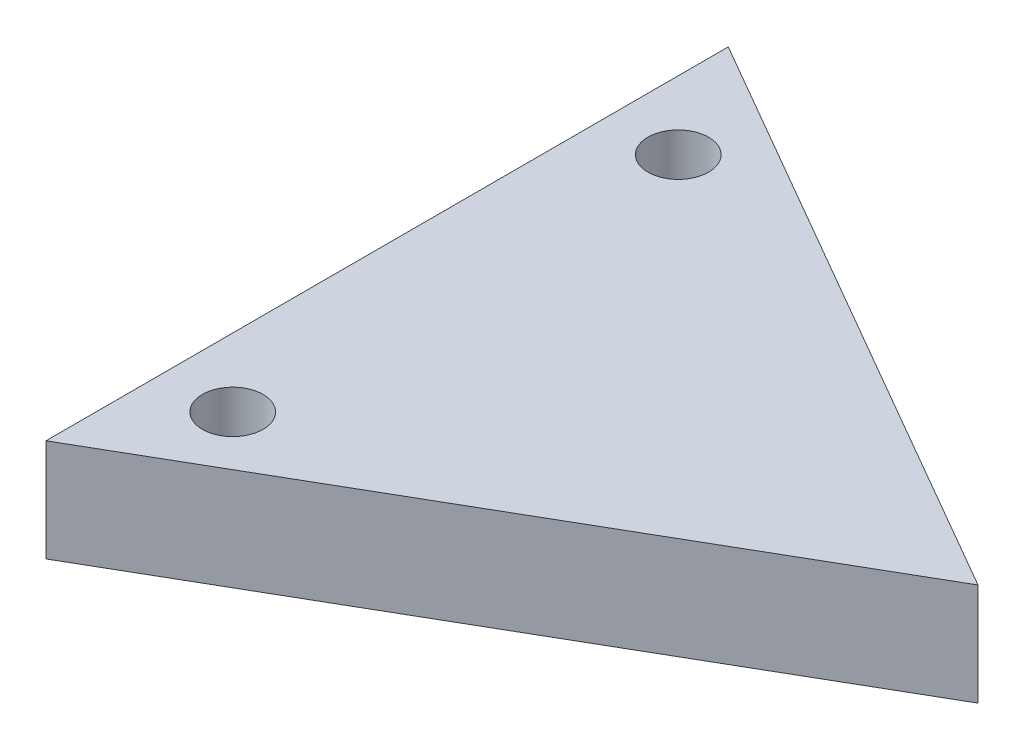
from build123d import *

# Parameters (mm, degrees)
EXTRUDE1_DEPTH  = 3
LPATTERN1_COUNT = 2
LPATTERN1_PITCH = 13.06


with BuildPart() as part:
    # Sketch1 → Extrude1 (new body)
    with BuildSketch(Plane(origin=(0, 0, 0), x_dir=(1, 0, 0), z_dir=(0, 1, 0))):
        Polygon((11.547005384, 0), (-5.773502692, 10), (-5.773502692, -10), align=None)
    extrude(amount=EXTRUDE1_DEPTH)

    # Sketch6 → #2-56 Tapped Hole1 (revolve, cut)
    with BuildSketch(Plane(origin=(-3.77, 3, -6.53), x_dir=(0, 0, 1), z_dir=(1, 0, 0))):
        Polygon((0, 0), (0, 7.17416509), (0.889, 6.64), (0.889, 0), align=None)
    f_2_56_tapped_hole1 = revolve(axis=Axis((-3.77, 9.35, -6.53), (0, -1, 0)), mode=Mode.SUBTRACT)

    # LPattern1: #2-56 Tapped Hole1 ×2
    with Locations(*[(0, 0, i * LPATTERN1_PITCH) for i in range(1, LPATTERN1_COUNT)]):
        add(f_2_56_tapped_hole1, mode=Mode.SUBTRACT)


solid = part.part
